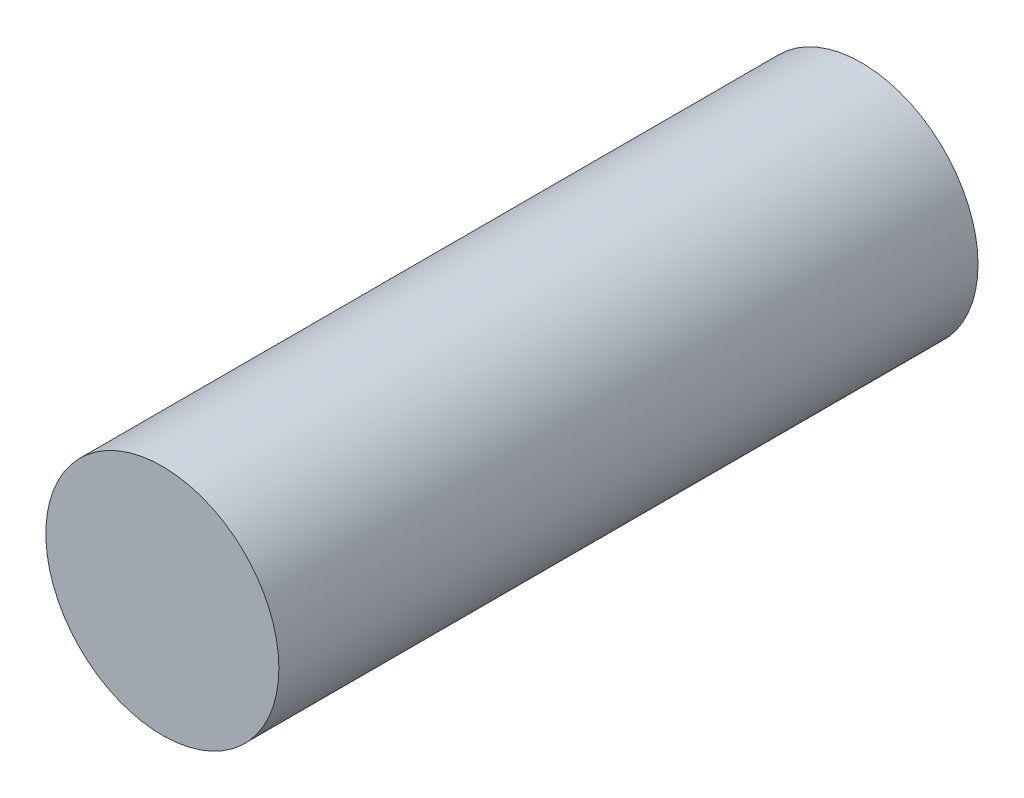
from build123d import *

# Parameters (mm, degrees)
SKETCH1_R           = 1
BOSS_EXTRUDE1_DEPTH = 6


with BuildPart() as part:
    # Sketch1 → Boss-Extrude1 (new body)
    with BuildSketch(Plane.XY):
        with Locations((0, 10.610944307)):
            Circle(SKETCH1_R)
    extrude(amount=BOSS_EXTRUDE1_DEPTH)


solid = part.part
